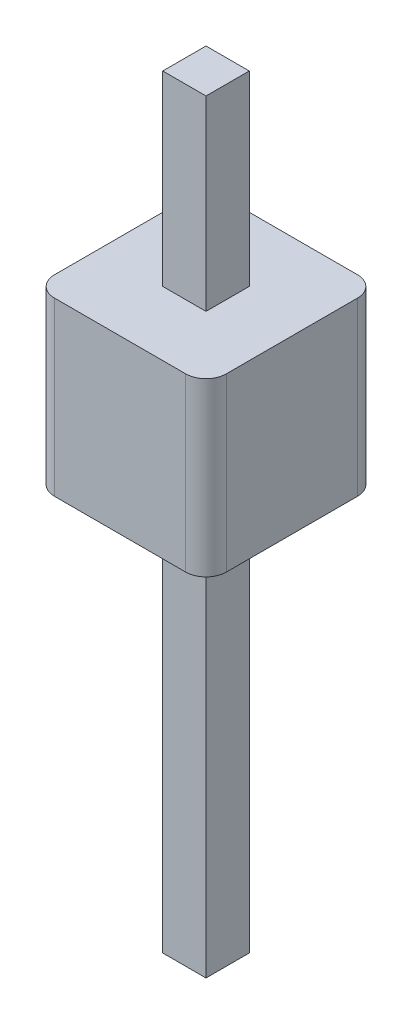
from build123d import *

# Parameters (mm, degrees)
SKETCH_1_W           = 0.64
SKETCH_1_H           = 0.64
EXTRUDE_1_DEPTH      = 2.54
EXTRUDE_2_DEPTH      = 5.3
EXTRUDE_2_DEPTH_BACK = 6
SKETCH_1_2_W         = 0.64
SKETCH_1_2_H         = 0.64


with BuildPart() as part:
    # Эскиз1 → Бобышка-Вытянуть1 (new body)
    with BuildSketch(Plane(origin=(0, 0, 0), x_dir=(1, 0, 0), z_dir=(0, 1, 0))):
        with BuildLine():
            Line((0.97, -1.27), (-0.97, -1.27))
            ThreePointArc((-0.97, -1.27), (-1.182132034, -1.182132034), (-1.27, -0.97))
            Line((-1.27, -0.97), (-1.27, 0.97))
            ThreePointArc((-1.27, 0.97), (-1.182132034, 1.182132034), (-0.97, 1.27))
            Line((-0.97, 1.27), (0.97, 1.27))
            ThreePointArc((0.97, 1.27), (1.182132034, 1.182132034), (1.27, 0.97))
            Line((1.27, 0.97), (1.27, -0.97))
            ThreePointArc((1.27, -0.97), (1.182132034, -1.182132034), (0.97, -1.27))
        make_face()
        Rectangle(SKETCH_1_W, SKETCH_1_H, mode=Mode.SUBTRACT)
    extrude(amount=EXTRUDE_1_DEPTH)

    # Эскиз1<2> → Бобышка-Вытянуть2 (add, two sides: drawn at the far end of the back side and taken through both)
    with BuildSketch(Plane(origin=(0, 0, 0), x_dir=(1, 0, 0), z_dir=(0, 1, 0)).offset(-EXTRUDE_2_DEPTH_BACK)):
        Rectangle(SKETCH_1_2_W, SKETCH_1_2_H)
    extrude(amount=EXTRUDE_2_DEPTH + EXTRUDE_2_DEPTH_BACK)


solid = part.part
